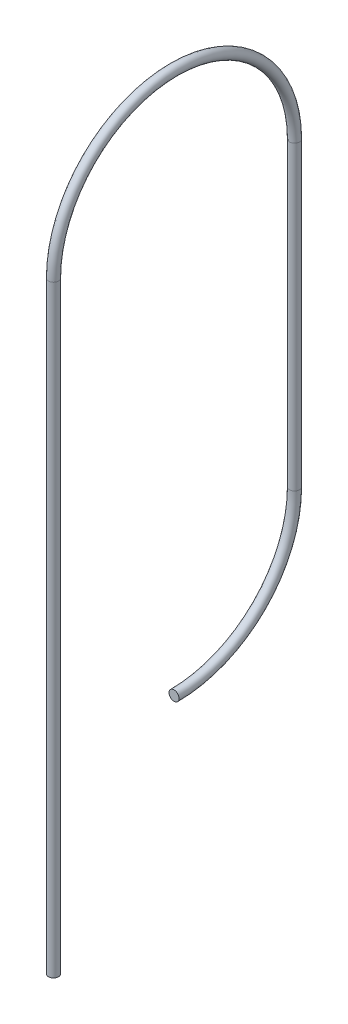
from build123d import *

# Parameters (mm, degrees)
SKETCH4_R = 1.25


with BuildPart() as part:
    # Sweep2: sweep along a path in Sketch3
    with BuildLine(Plane(origin=(0, 0, 0), x_dir=(0, 0, -1), z_dir=(1, 0, 0))) as sweep2_path:
        Line((0, 0), (0, 150))
        ThreePointArc((0, 150), (30, 180), (60, 150))
        Line((60, 150), (60, 75))
        ThreePointArc((60, 75), (51.215491763, 53.789085138), (30.006472715, 45.000000698))
    # Sketch4 → Sweep2 (sweep)
    with BuildSketch(Plane(origin=(0, 0, 0), x_dir=(1, 0, 0), z_dir=(0, 1, 0))):
        Circle(SKETCH4_R)
    sweep(path=sweep2_path.line)


solid = part.part
